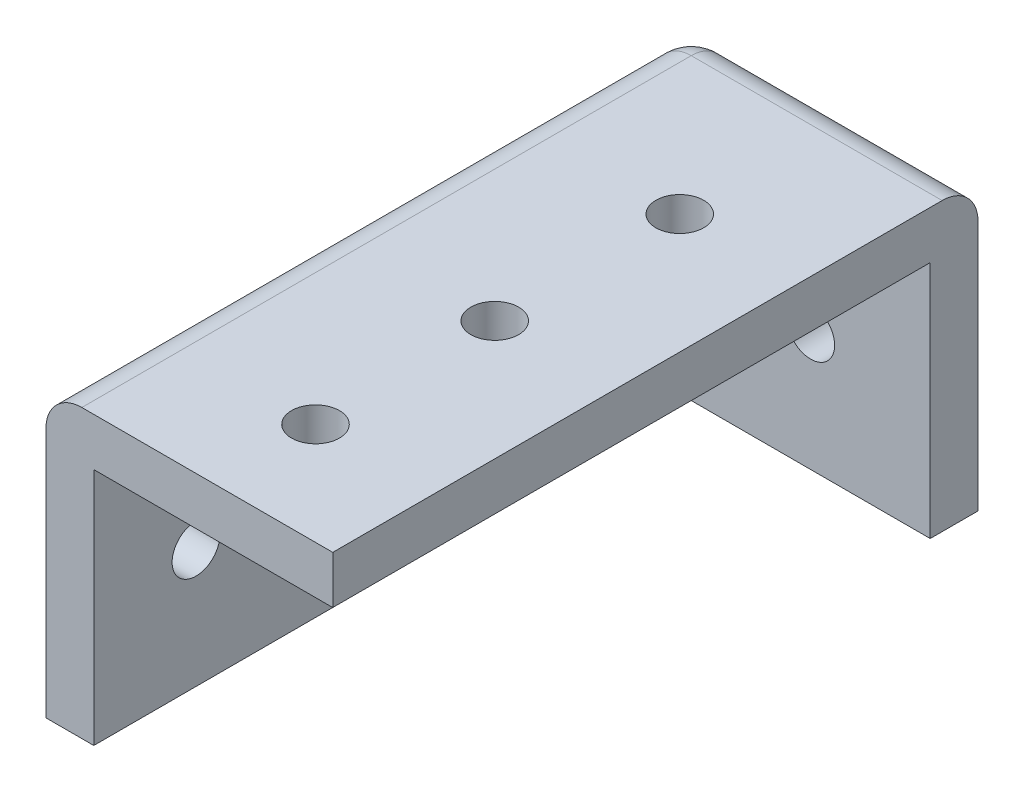
from build123d import *

# Parameters (mm, degrees)
BOSS_EXTRUDE1_DEPTH = 50
SKETCH2_W           = 24
SKETCH2_H           = 24
BOSS_EXTRUDE2_DEPTH = 4
SKETCH3_R           = 2
CUT_EXTRUDE1_DEPTH  = 4
SKETCH4_R           = 2
CUT_EXTRUDE2_DEPTH  = 4
FILLET1_R           = 3


with BuildPart() as part:
    # Sketch1 → Boss-Extrude1 (new body)
    with BuildSketch(Plane.XY):
        Polygon((0, 0), (0, 24), (24, 24), (24, 20), (4, 20), (4, 0), align=None)
    extrude(amount=BOSS_EXTRUDE1_DEPTH)

    # Sketch2 → Boss-Extrude2 (add)
    with BuildSketch(Plane(origin=(0, 0, 0), x_dir=(-1, 0, 0), z_dir=(0, 0, -1))):
        with Locations((-12, 12)):
            Rectangle(SKETCH2_W, SKETCH2_H)
    extrude(amount=BOSS_EXTRUDE2_DEPTH)

    # Sketch3 → Cut-Extrude1 (cut)
    with BuildSketch(Plane(origin=(0, 0, -4), x_dir=(-1, 0, 0), z_dir=(0, 0, -1))):
        with Locations((-14, 10)):
            Circle(SKETCH3_R)
    extrude(amount=-CUT_EXTRUDE1_DEPTH, mode=Mode.SUBTRACT)

    # Sketch4 → Cut-Extrude2 (cut)
    with BuildSketch(Plane(origin=(0, 24, 0), x_dir=(1, 0, 0), z_dir=(0, 1, 0))):
        with Locations((14, -26.445871018)):
            Circle(SKETCH4_R)
        with Locations((14, -10.960041792)):
            Circle(SKETCH4_R)
        with Locations((14, -41.445871018)):
            Circle(SKETCH4_R)
    cut_extrude2 = extrude(amount=-CUT_EXTRUDE2_DEPTH, mode=Mode.SUBTRACT)

    # Mirror1: Cut-Extrude2 across plane
    add(cut_extrude2.mirror(Plane(origin=(12, 12, 0), x_dir=(0, 0, 1), z_dir=(-0.707106781, -0.707106781, 0))), mode=Mode.SUBTRACT)

    # Fillet1
    fillet1_edges = [part.edges().sort_by_distance(p)[0] for p in [
        (0, 24, 23),
        (0, 12, -4),
        (12, 24, -4),
    ]]
    fillet(fillet1_edges, radius=FILLET1_R)


solid = part.part
